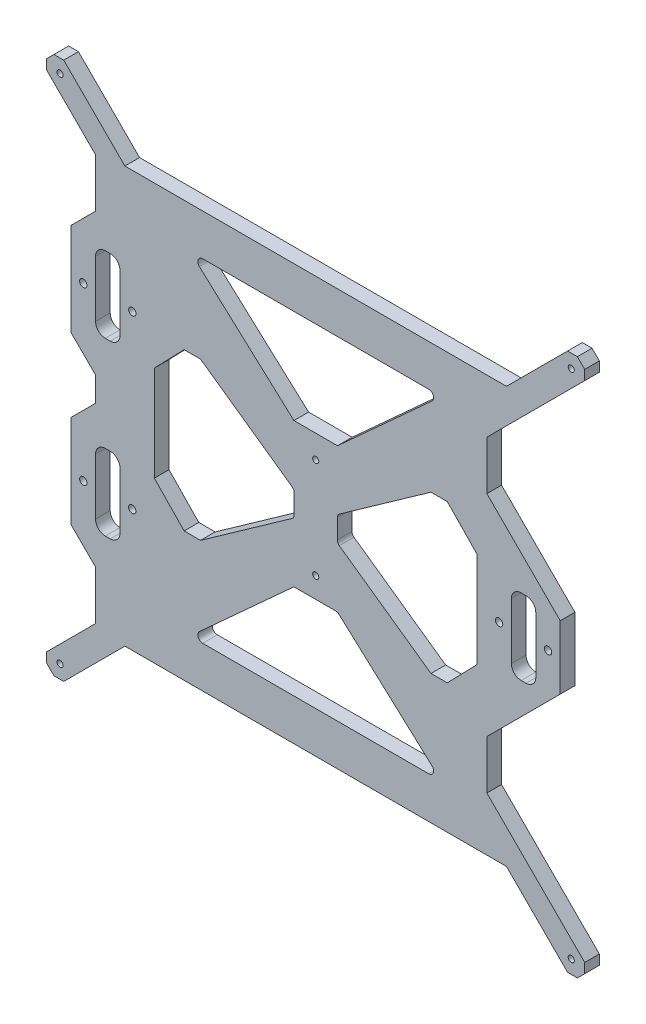
from build123d import *

# Parameters (mm, degrees)
FRAME_R             = 1.5
FRAME_R_2           = 1.25
BOSS_EXTRUDE1_DEPTH = 6


with BuildPart() as part:
    # FRAME → Boss-Extrude1 (new body)
    with BuildSketch(Plane.XY):
        Polygon((65, 325), (63, 325), (60, 322), (60, 320), (60, 318), (80, 298), (80, 278), (70, 268), (70, 230), (80, 220), (80, 210), (70, 200), (70, 162), (80, 152), (80, 132), (60, 112), (60, 108), (63, 105), (65, 105), (67, 105), (92, 130), (248, 130), (273, 105), (275, 105), (277, 105), (280, 108), (280, 112), (260, 132), (240, 152), (240, 172), (260, 192), (270, 202), (270, 228), (260, 238), (240, 258), (240, 278), (280, 318), (280, 321), (280, 322), (277, 325), (273, 325), (250, 302), (248, 300), (92, 300), (67, 325), align=None)
        with Locations((75, 250)):
            Circle(FRAME_R, mode=Mode.SUBTRACT)
        with Locations((95.037619408, 250)):
            Circle(FRAME_R, mode=Mode.SUBTRACT)
        with Locations((75, 180)):
            Circle(FRAME_R, mode=Mode.SUBTRACT)
        with Locations((95, 180)):
            Circle(FRAME_R, mode=Mode.SUBTRACT)
        with Locations((265, 215)):
            Circle(FRAME_R, mode=Mode.SUBTRACT)
        with Locations((245, 215)):
            Circle(FRAME_R, mode=Mode.SUBTRACT)
        with Locations((65.5, 319.5)):
            Circle(FRAME_R_2, mode=Mode.SUBTRACT)
        with Locations((274.5, 110.5)):
            Circle(FRAME_R_2, mode=Mode.SUBTRACT)
        with Locations((274.5, 319.5)):
            Circle(FRAME_R_2, mode=Mode.SUBTRACT)
        with Locations((65.5, 110.5)):
            Circle(FRAME_R_2, mode=Mode.SUBTRACT)
        with Locations((170.024675872, 194)):
            Circle(FRAME_R_2, mode=Mode.SUBTRACT)
        with Locations((170.024675872, 235)):
            Circle(FRAME_R_2, mode=Mode.SUBTRACT)
        with BuildLine():
            Line((161.216590497, 218.964796722), (161.216590497, 211.035203278))
            ThreePointArc((161.216590497, 211.035203278), (160.992764596, 210.115852653), (160.371384926, 209.402276511))
            Line((160.371384926, 209.402276511), (122.909474642, 182.909474642))
            Line((122.909474642, 182.909474642), (116.23015359, 182.909474642))
            Line((116.23015359, 182.909474642), (104.037619408, 195.501934511))
            Line((104.037619408, 195.501934511), (104.037619408, 234.498065489))
            Line((104.037619408, 234.498065489), (116.23015359, 247.090525358))
            Line((116.23015359, 247.090525358), (122.909474642, 247.090525358))
            Line((122.909474642, 247.090525358), (160.371384926, 220.597723489))
            ThreePointArc((160.371384926, 220.597723489), (160.992764596, 219.884147347), (161.216590497, 218.964796722))
        make_face(mode=Mode.SUBTRACT)
        with BuildLine():
            Line((122.471056888, 279.600410825), (161.114699893, 244.435797428))
            Line((161.114699893, 244.435797428), (178.934651851, 244.435797428))
            Line((178.934651851, 244.435797428), (217.578294856, 279.600410825))
            ThreePointArc((217.578294856, 279.600410825), (218.0975061, 281.801285282), (216.232236245, 283.079642455))
            Line((216.232236245, 283.079642455), (123.817115499, 283.079642455))
            ThreePointArc((123.817115499, 283.079642455), (121.951845644, 281.801285282), (122.471056888, 279.600410825))
        make_face(mode=Mode.SUBTRACT)
        with BuildLine():
            Line((217.139877102, 247.090525358), (179.677966818, 220.597723489))
            ThreePointArc((179.677966818, 220.597723489), (179.056587148, 219.884147347), (178.832761247, 218.964796722))
            Line((178.832761247, 218.964796722), (178.832761247, 211.035203278))
            ThreePointArc((178.832761247, 211.035203278), (179.056587148, 210.115852653), (179.677966818, 209.402276511))
            Line((179.677966818, 209.402276511), (217.139877102, 182.909474642))
            Line((217.139877102, 182.909474642), (223.819198154, 182.909474642))
            Line((223.819198154, 182.909474642), (236.011732336, 195.501934511))
            Line((236.011732336, 195.501934511), (236.011732336, 234.498065489))
            Line((236.011732336, 234.498065489), (223.819198154, 247.090525358))
            Line((223.819198154, 247.090525358), (217.139877102, 247.090525358))
        make_face(mode=Mode.SUBTRACT)
        with BuildLine():
            Line((217.578294856, 150.399589175), (178.934651851, 185.564202572))
            Line((178.934651851, 185.564202572), (161.114699893, 185.564202572))
            Line((161.114699893, 185.564202572), (122.471056888, 150.399589175))
            ThreePointArc((122.471056888, 150.399589175), (121.951845644, 148.198714718), (123.817115499, 146.920357545))
            Line((123.817115499, 146.920357545), (216.232236245, 146.920357545))
            ThreePointArc((216.232236245, 146.920357545), (218.0975061, 148.198714718), (217.578294856, 150.399589175))
        make_face(mode=Mode.SUBTRACT)
        with BuildLine():
            Line((80, 169), (80, 192))
            ThreePointArc((80, 192), (81.171572875, 194.828427125), (84, 196))
            Line((84, 196), (86, 196))
            ThreePointArc((86, 196), (88.828427125, 194.828427125), (90, 192))
            Line((90, 192), (90, 169))
            ThreePointArc((90, 169), (88.828427125, 166.171572875), (86, 165))
            Line((86, 165), (84, 165))
            ThreePointArc((84, 165), (81.171572875, 166.171572875), (80, 169))
        make_face(mode=Mode.SUBTRACT)
        with BuildLine():
            Line((80, 239.007036896), (80, 262.007036896))
            ThreePointArc((80, 262.007036896), (81.171572875, 264.835464021), (84, 266.007036896))
            Line((84, 266.007036896), (86, 266.007036896))
            ThreePointArc((86, 266.007036896), (88.828427125, 264.835464021), (90, 262.007036896))
            Line((90, 262.007036896), (90, 239.007036896))
            ThreePointArc((90, 239.007036896), (88.828427125, 236.178609771), (86, 235.007036896))
            Line((86, 235.007036896), (84, 235.007036896))
            ThreePointArc((84, 235.007036896), (81.171572875, 236.178609771), (80, 239.007036896))
        make_face(mode=Mode.SUBTRACT)
        with BuildLine():
            Line((250, 202.862876393), (250, 225.862876393))
            ThreePointArc((250, 225.862876393), (251.171572875, 228.691303518), (254, 229.862876393))
            Line((254, 229.862876393), (256, 229.862876393))
            ThreePointArc((256, 229.862876393), (258.828427125, 228.691303518), (260, 225.862876393))
            Line((260, 225.862876393), (260, 202.862876393))
            ThreePointArc((260, 202.862876393), (258.828427125, 200.034449268), (256, 198.862876393))
            Line((256, 198.862876393), (254, 198.862876393))
            ThreePointArc((254, 198.862876393), (251.171572875, 200.034449268), (250, 202.862876393))
        make_face(mode=Mode.SUBTRACT)
    extrude(amount=BOSS_EXTRUDE1_DEPTH)


solid = part.part
